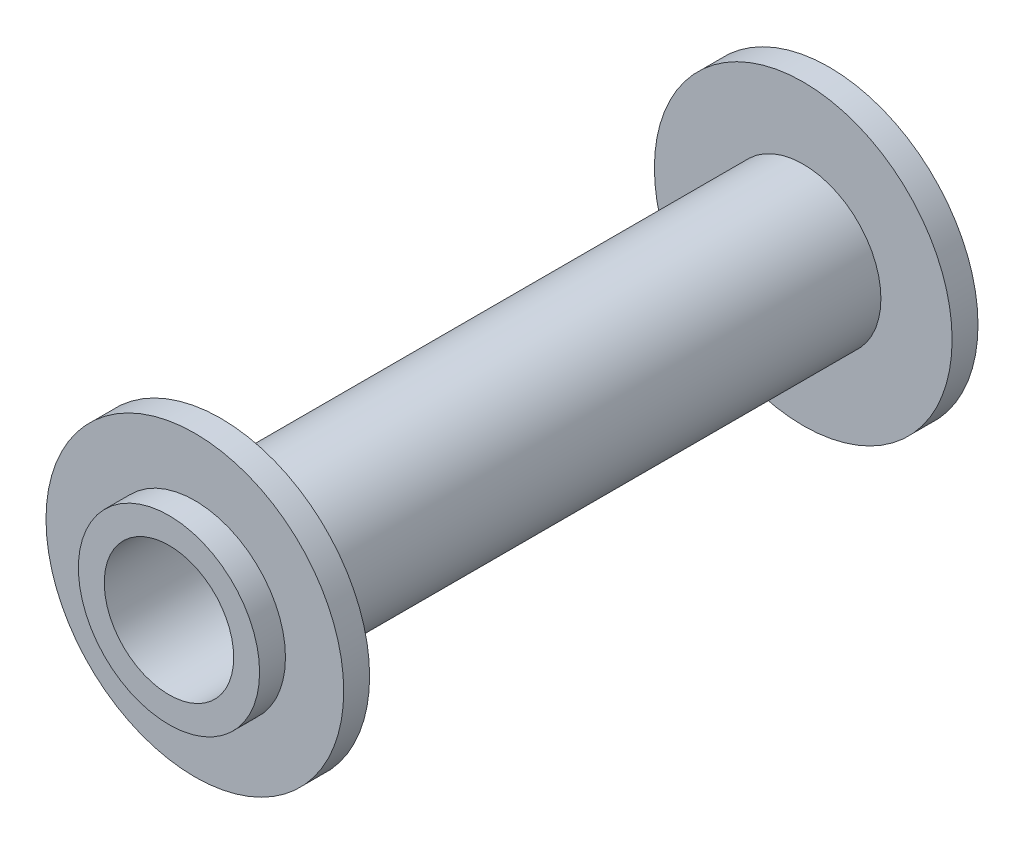
from build123d import *


with BuildPart() as part:
    # Sketch2 → Revolve1 (revolve)
    with BuildSketch(Plane(origin=(0, 0, 0), x_dir=(0, 0, -1), z_dir=(1, 0, 0))):
        Polygon((0, 5), (0, 7), (2, 7), (2, 11.5), (4, 11.5), (4, 6), (49, 6), (49, 11.5), (51, 11.5), (51, 7), (53, 7), (53, 5), align=None)
    revolve(axis=Axis((0, 0, 0), (0, 0, -1)))


solid = part.part
